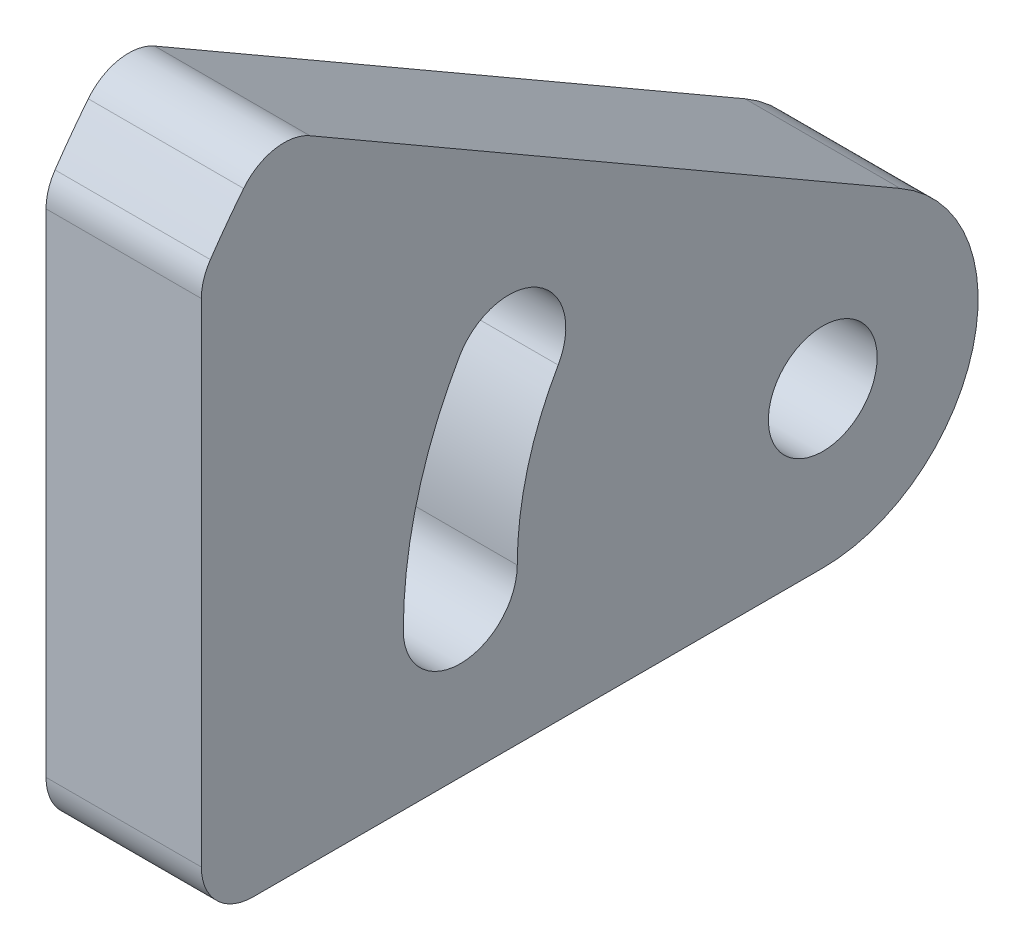
from build123d import *

# Parameters (mm, degrees)
SKETCH_8_R          = 1.05
EXTRUDE_4_DEPTH     = 1.5
SKETCH_14_W         = 2.317821063
SKETCH_14_H         = 10.810249676
CUT_EXTRUDE_3_DEPTH = 4
CUT_EXTRUDE_5_DEPTH = 4
FILLET_3_R          = 1


with BuildPart() as part:
    # 草图8 → 凸台-拉伸4 (new body, symmetric)
    with BuildSketch(Plane(origin=(0, 0, 0), x_dir=(0, 0, -1), z_dir=(1, 0, 0))):
        with BuildLine():
            Line((1.5, 2.598076211), (-10.624355653, 9.598076211))
            ThreePointArc((-10.624355653, 9.598076211), (-13.829953141, 3.705724776), (-14, -3))
            Line((-14, -3), (0, -3))
            ThreePointArc((0, -3), (2.897777479, -0.776457135), (1.5, 2.598076211))
        make_face()
        Circle(SKETCH_8_R, mode=Mode.SUBTRACT)
    extrude(amount=EXTRUDE_4_DEPTH, both=True)

    # 草图14 → 切除-拉伸3 (cut, through all)
    with BuildSketch(Plane(origin=(1.5, 0, 0), x_dir=(0, 0, -1), z_dir=(1, 0, 0))):
        with Locations((-13.158910532, 2.405124838)):
            Rectangle(SKETCH_14_W, SKETCH_14_H)
    extrude(amount=-CUT_EXTRUDE_3_DEPTH, mode=Mode.SUBTRACT)

    # 草图17 → 切除-拉伸5 (cut, through all)
    with BuildSketch(Plane(origin=(1.5, 0, 0), x_dir=(0, 0, -1), z_dir=(1, 0, 0))):
        with BuildLine():
            ThreePointArc((-7.014805771, 4.05), (-7.823999193, 2.096434265), (-8.1, 0))
            ThreePointArc((-8.1, 0), (-7, -1.1), (-5.9, 0))
            ThreePointArc((-5.9, 0), (-5.698962375, 1.527032366), (-5.109549882, 2.95))
            ThreePointArc((-5.109549882, 2.95), (-5.512177826, 4.452627944), (-7.014805771, 4.05))
        make_face()
    extrude(amount=-CUT_EXTRUDE_5_DEPTH, mode=Mode.SUBTRACT)

    # 圆角3
    fillet_3_edges = [part.edges().sort_by_distance(p)[0] for p in [
        (0, -3, 12),
        (0, 7.810249676, 12),
        (0, 9.598076211, 10.624355653),
    ]]
    fillet(fillet_3_edges, radius=FILLET_3_R)


solid = part.part
